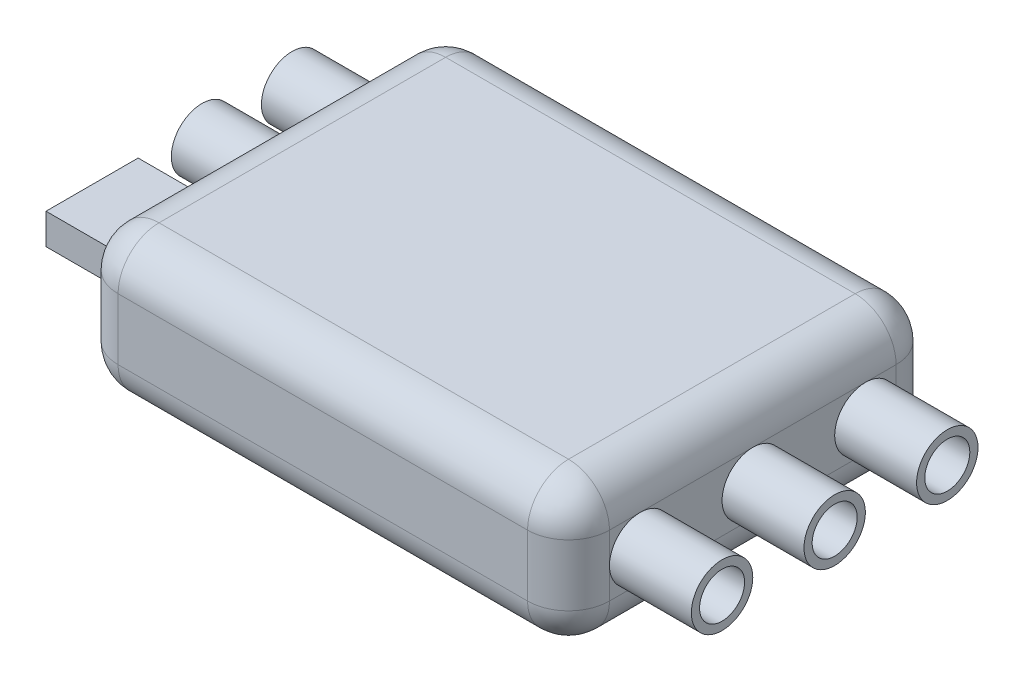
from build123d import *

# Parameters (mm, degrees)
BOSS_EXTRUDE1_DEPTH = 7
FILLET1_R           = 2
SKETCH2_R           = 1.5
SKETCH2_R_2         = 1.1
BOSS_EXTRUDE2_DEPTH = 4
SKETCH3_R           = 1.5
SKETCH3_R_2         = 1.1
SKETCH3_W           = 4.5
SKETCH3_H           = 1.5
BOSS_EXTRUDE3_DEPTH = 4


with BuildPart() as part:
    # Sketch1 → Boss-Extrude1 (new body)
    with BuildSketch(Plane(origin=(0, 0, 0), x_dir=(1, 0, 0), z_dir=(0, 1, 0))):
        with BuildLine():
            Line((-10, 9), (10, 9))
            ThreePointArc((10, 9), (11.414213562, 8.414213562), (12, 7))
            Line((12, 7), (12, -7))
            ThreePointArc((12, -7), (11.414213562, -8.414213562), (10, -9))
            Line((10, -9), (-10, -9))
            ThreePointArc((-10, -9), (-11.414213562, -8.414213562), (-12, -7))
            Line((-12, -7), (-12, 7))
            ThreePointArc((-12, 7), (-11.414213562, 8.414213562), (-10, 9))
        make_face()
    extrude(amount=BOSS_EXTRUDE1_DEPTH)

    # Fillet1
    fillet1_edges = [part.edges().sort_by_distance(p)[0] for p in [
        (12, 0, 0),
        (11.414213562, 0, 8.414213562),
        (0, 0, 9),
        (-11.414213562, 0, 8.414213562),
        (11.414213562, 7, 8.414213562),
        (12, 7, 0),
        (11.414213562, 7, -8.414213562),
        (0, 7, -9),
        (-11.414213562, 7, -8.414213562),
        (-12, 7, 0),
        (-11.414213562, 7, 8.414213562),
        (-12, 0, 0),
        (0, 7, 9),
        (-11.414213562, 0, -8.414213562),
        (0, 0, -9),
        (11.414213562, 0, -8.414213562),
    ]]
    fillet(fillet1_edges, radius=FILLET1_R)

    # Sketch2 → Boss-Extrude2 (add)
    with BuildSketch(Plane(origin=(12, 0, 0), x_dir=(0, 0, -1), z_dir=(1, 0, 0))):
        with Locations((0, 3.5)):
            Circle(SKETCH2_R)
        with Locations((0, 3.5)):
            Circle(SKETCH2_R_2, mode=Mode.SUBTRACT)
        with Locations((-5.5, 3.5)):
            Circle(SKETCH2_R)
        with Locations((-5.5, 3.5)):
            Circle(SKETCH2_R_2, mode=Mode.SUBTRACT)
        with Locations((5.5, 3.5)):
            Circle(SKETCH2_R)
        with Locations((5.5, 3.5)):
            Circle(SKETCH2_R_2, mode=Mode.SUBTRACT)
    extrude(amount=BOSS_EXTRUDE2_DEPTH)

    # Sketch3 → Boss-Extrude3 (add)
    with BuildSketch(Plane.ZY.offset(12)):
        with Locations((-5.5, 3.5)):
            Circle(SKETCH3_R)
        with Locations((-5.5, 3.5)):
            Circle(SKETCH3_R_2, mode=Mode.SUBTRACT)
        with Locations((-1.1, 3.5)):
            Circle(SKETCH3_R)
        with Locations((-1.1, 3.5)):
            Circle(SKETCH3_R_2, mode=Mode.SUBTRACT)
        with Locations((4.270370243, 3.5)):
            Rectangle(SKETCH3_W, SKETCH3_H)
    extrude(amount=BOSS_EXTRUDE3_DEPTH)


solid = part.part
